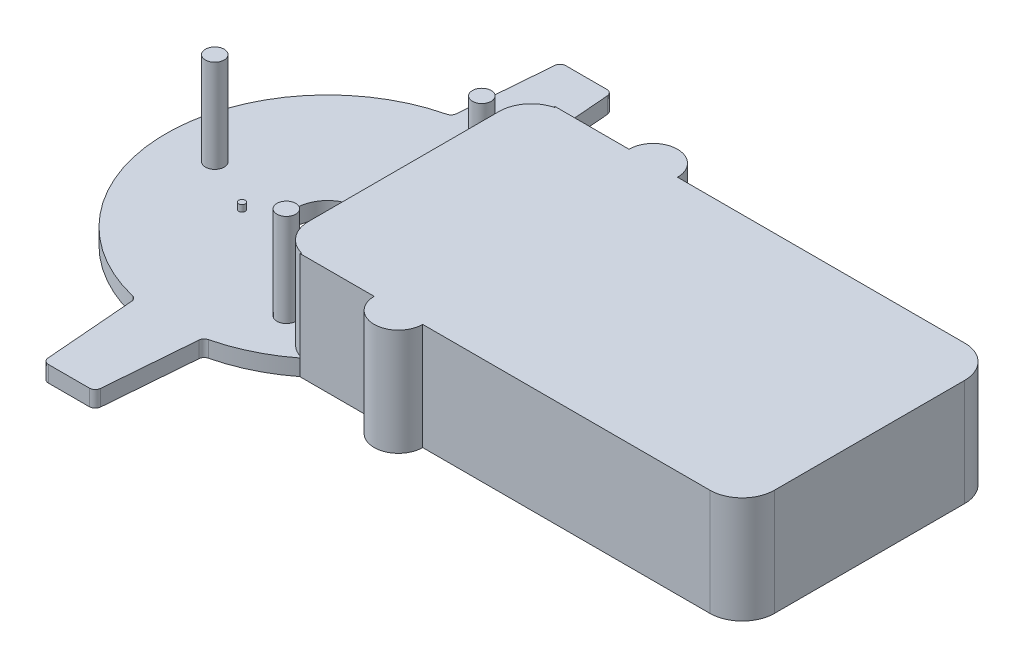
from build123d import *

# Parameters (mm, degrees)
BOSS_EXTRUDE2_DEPTH = 33
CUT_EXTRUDE1_DEPTH  = 28
SKETCH3_R           = 10
CUT_EXTRUDE2_DEPTH  = 6
SKETCH5_R           = 2.9
BOSS_EXTRUDE3_DEPTH = 28.7
CIRPATTERN1_COUNT   = 3
SKETCH6_R           = 1
BOSS_EXTRUDE4_DEPTH = 2


with BuildPart() as part:
    # Sketch1 → Boss-Extrude2 (new body)
    with BuildSketch(Plane(origin=(0, 0, 0), x_dir=(1, 0, 0), z_dir=(0, 1, 0))):
        with BuildLine():
            Line((68.783761953, -39.4), (157.583761953, -39.4))
            ThreePointArc((157.583761953, -39.4), (164.654829765, -36.471067812), (167.583761953, -29.4))
            Line((167.583761953, -29.4), (167.583761953, 29.4))
            ThreePointArc((167.583761953, 29.4), (164.654829765, 36.471067812), (157.583761953, 39.4))
            Line((157.583761953, 39.4), (68.783761953, 39.4))
            ThreePointArc((68.783761953, 39.4), (61.283761953, 46.9), (53.783761953, 39.4))
            Line((53.783761953, 39.4), (30.783761953, 39.4))
            ThreePointArc((30.783761953, 39.4), (21.761629353, 45.015902611), (11.75641742, 48.598216525))
            ThreePointArc((11.75641742, 48.598216525), (10.817431593, 49.174777372), (10.394956543, 50.192437248))
            Line((10.394956543, 50.192437248), (8.132117785, 78.35566571))
            ThreePointArc((8.132117785, 78.35566571), (7.562644675, 79.526094921), (6.350366597, 80))
            Line((6.350366597, 80), (-6.350366597, 80))
            ThreePointArc((-6.350366597, 80), (-7.562644675, 79.526094921), (-8.132117785, 78.35566571))
            Line((-8.132117785, 78.35566571), (-10.394956543, 50.192437248))
            ThreePointArc((-10.394956543, 50.192437248), (-10.817431593, 49.174777372), (-11.75641742, 48.598216525))
            ThreePointArc((-11.75641742, 48.598216525), (-50, 0), (-11.75641742, -48.598216525))
            ThreePointArc((-11.75641742, -48.598216525), (-10.817431593, -49.174777372), (-10.394956543, -50.192437248))
            Line((-10.394956543, -50.192437248), (-8.132117785, -78.35566571))
            ThreePointArc((-8.132117785, -78.35566571), (-7.562644675, -79.526094921), (-6.350366597, -80))
            Line((-6.350366597, -80), (6.350366597, -80))
            ThreePointArc((6.350366597, -80), (7.562644675, -79.526094921), (8.132117785, -78.35566571))
            Line((8.132117785, -78.35566571), (10.394956543, -50.192437248))
            ThreePointArc((10.394956543, -50.192437248), (10.817431593, -49.174777372), (11.75641742, -48.598216525))
            ThreePointArc((11.75641742, -48.598216525), (21.761629353, -45.015902611), (30.783761953, -39.4))
            Line((30.783761953, -39.4), (53.783761953, -39.4))
            ThreePointArc((53.783761953, -39.4), (61.283761953, -46.9), (68.783761953, -39.4))
        make_face()
    extrude(amount=BOSS_EXTRUDE2_DEPTH)

    # Sketch2 → Cut-Extrude1 (cut)
    with BuildSketch(Plane(origin=(0, 33, 0), x_dir=(1, 0, 0), z_dir=(0, 1, 0))):
        with BuildLine():
            Line((23.583761953, 29.4), (23.583761953, -29.4))
            ThreePointArc((23.583761953, -29.4), (25.702607781, -35.555274886), (31.161243737, -39.102134069))
            ThreePointArc((31.161243737, -39.102134069), (22.770762082, -44.513957297), (13.472291615, -48.150777342))
            Line((13.472291615, -48.150777342), (13.472291615, -85.250601705))
            Line((13.472291615, -85.250601705), (-13.472291615, -85.250601705))
            Line((-13.472291615, -85.250601705), (-13.472291615, -48.150777342))
            ThreePointArc((-13.472291615, -48.150777342), (-50, 0), (-13.472291615, 48.150777342))
            Line((-13.472291615, 48.150777342), (-13.472291615, 85.250601705))
            Line((-13.472291615, 85.250601705), (13.472291615, 85.250601705))
            Line((13.472291615, 85.250601705), (13.472291615, 48.150777342))
            ThreePointArc((13.472291615, 48.150777342), (22.770762082, 44.513957297), (31.161243737, 39.102134069))
            ThreePointArc((31.161243737, 39.102134069), (25.702607781, 35.555274886), (23.583761953, 29.4))
        make_face()
    extrude(amount=-CUT_EXTRUDE1_DEPTH, mode=Mode.SUBTRACT)

    # Sketch3 → Cut-Extrude2 (cut, through all)
    with BuildSketch(Plane(origin=(0, 5, 0), x_dir=(1, 0, 0), z_dir=(0, 1, 0))):
        Circle(SKETCH3_R)
    extrude(amount=-CUT_EXTRUDE2_DEPTH, mode=Mode.SUBTRACT)

    # Sketch5 → Boss-Extrude3 (add)
    with BuildSketch(Plane(origin=(0, 5, 0), x_dir=(1, 0, 0), z_dir=(0, 1, 0))):
        with Locations((-34.9, 0)):
            Circle(SKETCH5_R)
    boss_extrude3 = extrude(amount=BOSS_EXTRUDE3_DEPTH)

    # CirPattern1: Boss-Extrude3 ×3 about axis
    cirpattern1_axis = Axis((0, 0, 0), (0, 1, 0))
    for i in range(1, CIRPATTERN1_COUNT):
        add(boss_extrude3.rotate(cirpattern1_axis, i * 360 / CIRPATTERN1_COUNT))

    # Sketch6 → Boss-Extrude4 (add)
    with BuildSketch(Plane(origin=(0, 5, 0), x_dir=(1, 0, 0), z_dir=(0, 1, 0))):
        with Locations((-17.896238047, -8.587616886)):
            Circle(SKETCH6_R)
    extrude(amount=BOSS_EXTRUDE4_DEPTH)


solid = part.part
